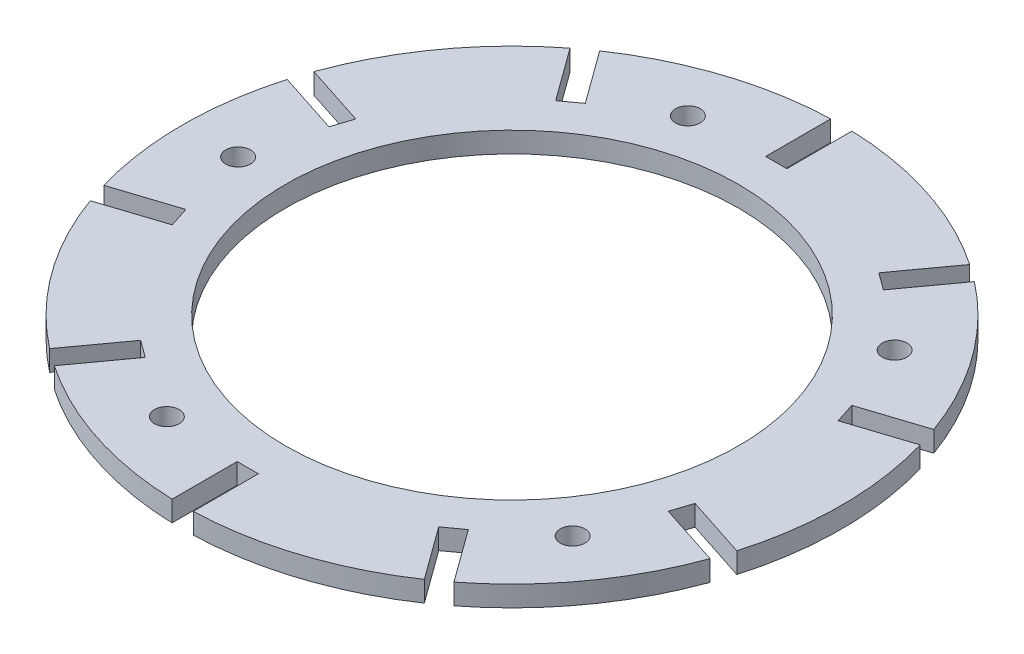
from build123d import *

# Parameters (mm, degrees)
ESQUISSE1_R                  = 160
ESQUISSE1_R_2                = 110
BOSS_EXTRU_1_DEPTH           = 10
ESQUISSE2_W                  = 10.3
ESQUISSE2_H                  = 31.7
ENL_V_MAT_EXTRU_2_DEPTH      = 10
ESQUISSE3_R                  = 6
ENL_V_MAT_EXTRU_3_DEPTH      = 11
R_P_TITION_CIRCULAIRE1_COUNT = 10
R_P_TITION_CIRCULAIRE2_COUNT = 5


with BuildPart() as part:
    # Esquisse1 → Boss.-Extru.1 (new body)
    with BuildSketch(Plane(origin=(0, 0, 0), x_dir=(1, 0, 0), z_dir=(0, 1, 0))):
        with Locations(Location((0, 0, 0), (0, 0, 270))):  # turned: the seam where the file's is
            Circle(ESQUISSE1_R)
        with Locations(Location((0, 0, 0), (0, 0, 270))):  # turned: the seam where the file's is
            Circle(ESQUISSE1_R_2, mode=Mode.SUBTRACT)
    extrude(amount=BOSS_EXTRU_1_DEPTH)

    # Esquisse2 → Enl_v. mat.-Extru.2 (cut)
    with BuildSketch(Plane(origin=(0, 10, 0), x_dir=(1, 0, 0), z_dir=(0, 1, 0))):
        with Locations((0, -144.15)):
            Rectangle(ESQUISSE2_W, ESQUISSE2_H)
    enl_v_mat_extru_2 = extrude(amount=-ENL_V_MAT_EXTRU_2_DEPTH, mode=Mode.SUBTRACT)

    # Esquisse3 → Enl_v. mat.-Extru.3 (cut, through all)
    with BuildSketch(Plane(origin=(0, 10, 0), x_dir=(1, 0, 0), z_dir=(0, 1, 0))):
        with Locations(Location((-41.099260252, -126.490516667, 0), (0, 0, 270))):  # turned: the seam where the file's is
            Circle(ESQUISSE3_R)
    enl_v_mat_extru_3 = extrude(amount=-ENL_V_MAT_EXTRU_3_DEPTH, mode=Mode.SUBTRACT)

    # R_p_tition circulaire1: Enl_v. mat.-Extru.2 ×10 about axis
    r_p_tition_circulaire1_axis = Axis((0, 0, 0), (0, 1, 0))
    for i in range(1, R_P_TITION_CIRCULAIRE1_COUNT):
        add(enl_v_mat_extru_2.rotate(r_p_tition_circulaire1_axis, i * 360 / R_P_TITION_CIRCULAIRE1_COUNT), mode=Mode.SUBTRACT)

    # R_p_tition circulaire2: Enl_v. mat.-Extru.3 ×5 about axis
    r_p_tition_circulaire2_axis = Axis((0, 0, 0), (0, 1, 0))
    for i in range(1, R_P_TITION_CIRCULAIRE2_COUNT):
        add(enl_v_mat_extru_3.rotate(r_p_tition_circulaire2_axis, i * 360 / R_P_TITION_CIRCULAIRE2_COUNT), mode=Mode.SUBTRACT)


solid = part.part
